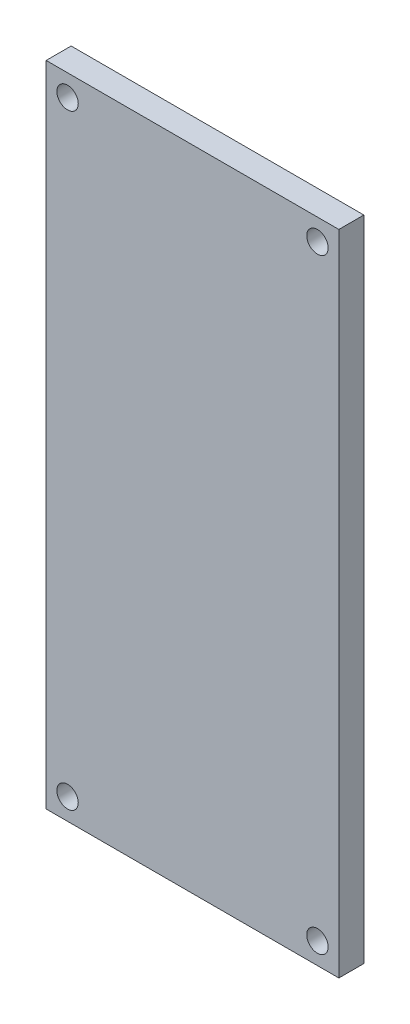
from build123d import *

# Parameters (mm, degrees)
SKETCH1_W               = 20.5
SKETCH1_H               = 45.4
EXTRUDE1_DEPTH          = 1.75
SKETCH2_R               = 0.75
CUT_EXTRUDE1_DEPTH      = 1.75
MIRROR2_COPY_1_SKETCH_R = 0.75
MIRROR2_COPY_1_DEPTH    = 1.75


with BuildPart() as part:
    # Sketch1 → Extrude1 (new body)
    with BuildSketch(Plane.XY):
        Rectangle(SKETCH1_W, SKETCH1_H)
    extrude(amount=EXTRUDE1_DEPTH)

    # Sketch2 → Cut-Extrude1 (cut)
    with BuildSketch(Plane.XY.offset(1.75)):
        with Locations((8.75, -21.2)):
            Circle(SKETCH2_R)
    cut_extrude1 = extrude(amount=-CUT_EXTRUDE1_DEPTH, mode=Mode.SUBTRACT)

    # Mirror1: Cut-Extrude1 across plane
    add(cut_extrude1.mirror(Plane(origin=(0, 0, 0), x_dir=(0, 0, 1), z_dir=(1, 0, 0))), mode=Mode.SUBTRACT)

    # Mirror2: Cut-Extrude1 across plane
    add(cut_extrude1.mirror(Plane.ZX), mode=Mode.SUBTRACT)

    # Mirror2 copy 1 sketch → Mirror2 copy 1 (cut)
    with BuildSketch(Plane(origin=(0, 0, 1.75), x_dir=(-1, 0, 0), z_dir=(0, 0, 1))):
        with Locations((8.75, -21.2)):
            Circle(MIRROR2_COPY_1_SKETCH_R)
    extrude(amount=-MIRROR2_COPY_1_DEPTH, mode=Mode.SUBTRACT)


solid = part.part
